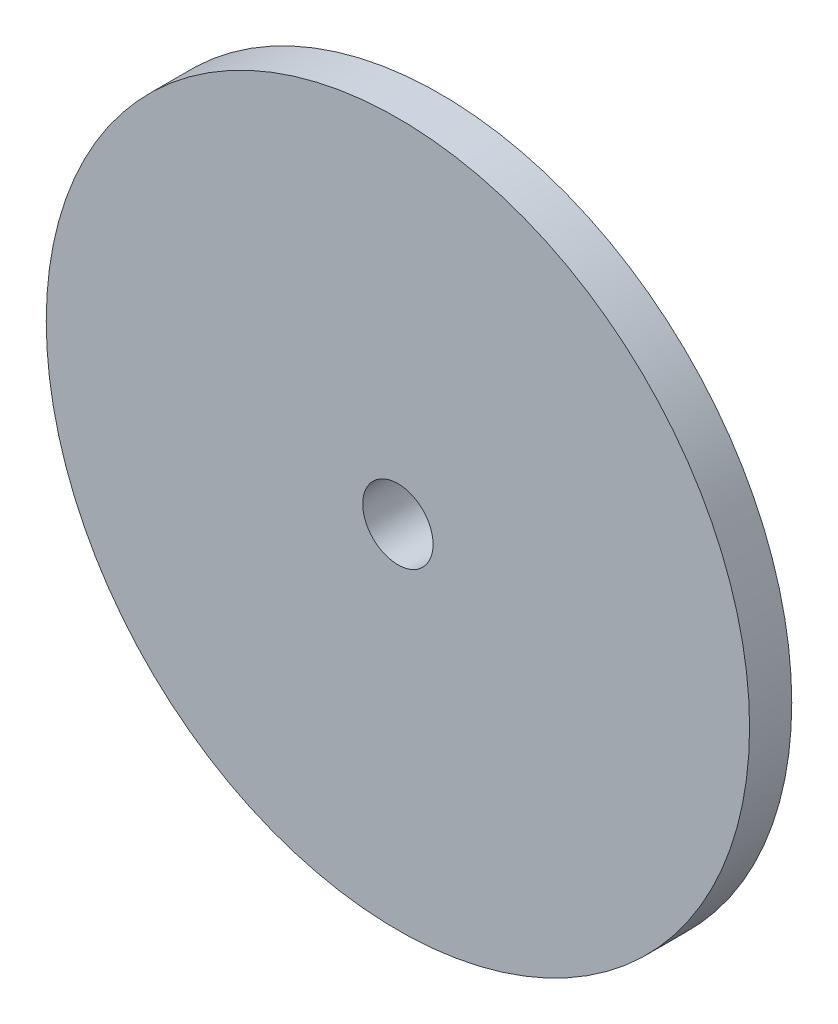
from build123d import *

# Parameters (mm, degrees)
SKETCH1_R           = 6
SKETCH1_R_2         = 1.25
BOSS_EXTRUDE1_DEPTH = 0.4
BOSS_EXTRUDE2_START = 1.5
SKETCH1_3_R         = 12.5
SKETCH1_3_R_2       = 1.25
BOSS_EXTRUDE2_DEPTH = 1.5


with BuildPart() as part:
    # Sketch1 → Boss-Extrude1 (new body)
    with BuildSketch(Plane.XY):
        with Locations((-27.262378968, 0)):
            Circle(SKETCH1_R)
        with Locations((-27.262378968, 0)):
            Circle(SKETCH1_R_2, mode=Mode.SUBTRACT)
    extrude(amount=-BOSS_EXTRUDE1_DEPTH)

    # Sketch1_3 → Boss-Extrude2 (add)
    with BuildSketch(Plane.XY.offset(BOSS_EXTRUDE2_START)):
        with Locations((-27.262378968, 0)):
            Circle(SKETCH1_3_R)
        with Locations((-27.262378968, 0)):
            Circle(SKETCH1_3_R_2, mode=Mode.SUBTRACT)
    extrude(amount=-BOSS_EXTRUDE2_DEPTH)


solid = part.part
